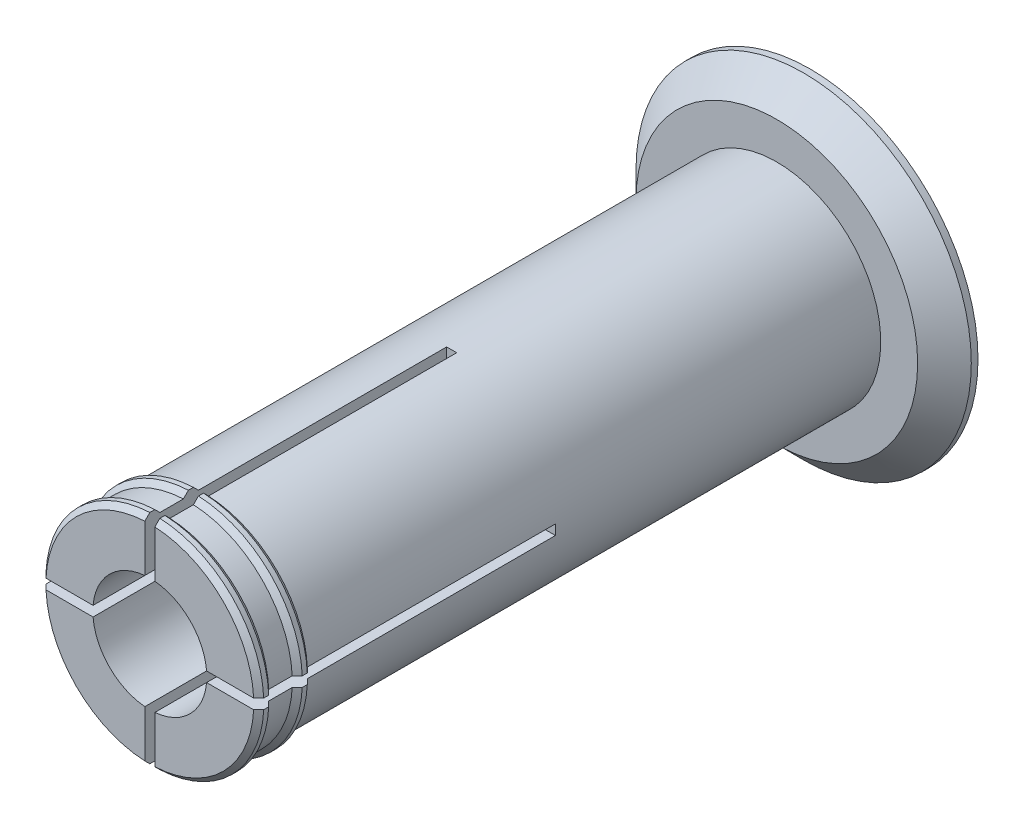
from build123d import *

# Parameters (mm, degrees)
AXLE_BASE_SKETCH_R        = 15.5
AXLE_DEPTH                = 93.5
GUARD_BASE_R              = 25
GUARD_DEPTH               = 5
INNER_AXLE_HOLE_BASE_R    = 8.5
INNER_AXLE_HOLE_DEPTH     = 99.5
BEND_ROOM_BASE_W          = 1.5
BEND_ROOM_BASE_H          = 50
BEND_ROOM_1_DEPTH         = 45
BEND_ROOM_2_COUNT         = 2
BEND_ROOM_2_ANGLE         = 90
EASY_REMOVAL_CHAMFER_SIZE = 4


with BuildPart() as part:
    # Axle base sketch → Axle (new body)
    with BuildSketch(Plane.XY):
        Circle(AXLE_BASE_SKETCH_R)
    extrude(amount=AXLE_DEPTH)

    # Guard base → Guard (add)
    with BuildSketch(Plane(origin=(0, 0, 0), x_dir=(-1, 0, 0), z_dir=(0, 0, -1))):
        Circle(GUARD_BASE_R)
    extrude(amount=GUARD_DEPTH)

    # Inner axle hole base → Inner axle hole (cut, through all)
    with BuildSketch(Plane.XY.offset(93.5)):
        Circle(INNER_AXLE_HOLE_BASE_R)
    extrude(amount=-INNER_AXLE_HOLE_DEPTH, mode=Mode.SUBTRACT)

    # Mate ring base → Mate rings (revolve)
    with BuildSketch(Plane(origin=(0, 0, 0), x_dir=(1, 0, 0), z_dir=(0, 1, 0))):
        Polygon((15.5, -93.5), (16.25, -92.75), (16.25, -92), (15.5, -91.25), align=None)
        Polygon((15.5, -87.75), (16.25, -87), (16.25, -86.25), (15.5, -85.5), align=None)
    revolve(axis=Axis((0, 0, 0), (0, 0, -1)))

    # Bend room base → Bend room 1 (cut)
    with BuildSketch(Plane.XY.offset(93.5)):
        Rectangle(BEND_ROOM_BASE_W, BEND_ROOM_BASE_H)
    bend_room_1 = extrude(amount=-BEND_ROOM_1_DEPTH, mode=Mode.SUBTRACT)

    # Bend room 2: Bend room 1 ×2 about axis
    bend_room_2_axis = Axis((0, 0, 0), (0, 0, -1))
    for i in range(1, BEND_ROOM_2_COUNT):
        add(bend_room_1.rotate(bend_room_2_axis, i * BEND_ROOM_2_ANGLE / (BEND_ROOM_2_COUNT - 1)), mode=Mode.SUBTRACT)

    # Easy removal chamfer
    easy_removal_chamfer_edges = [part.edges().sort_by_distance(p)[0] for p in [
        (25, 0, 0),
    ]]
    chamfer(easy_removal_chamfer_edges, length=EASY_REMOVAL_CHAMFER_SIZE)


solid = part.part
